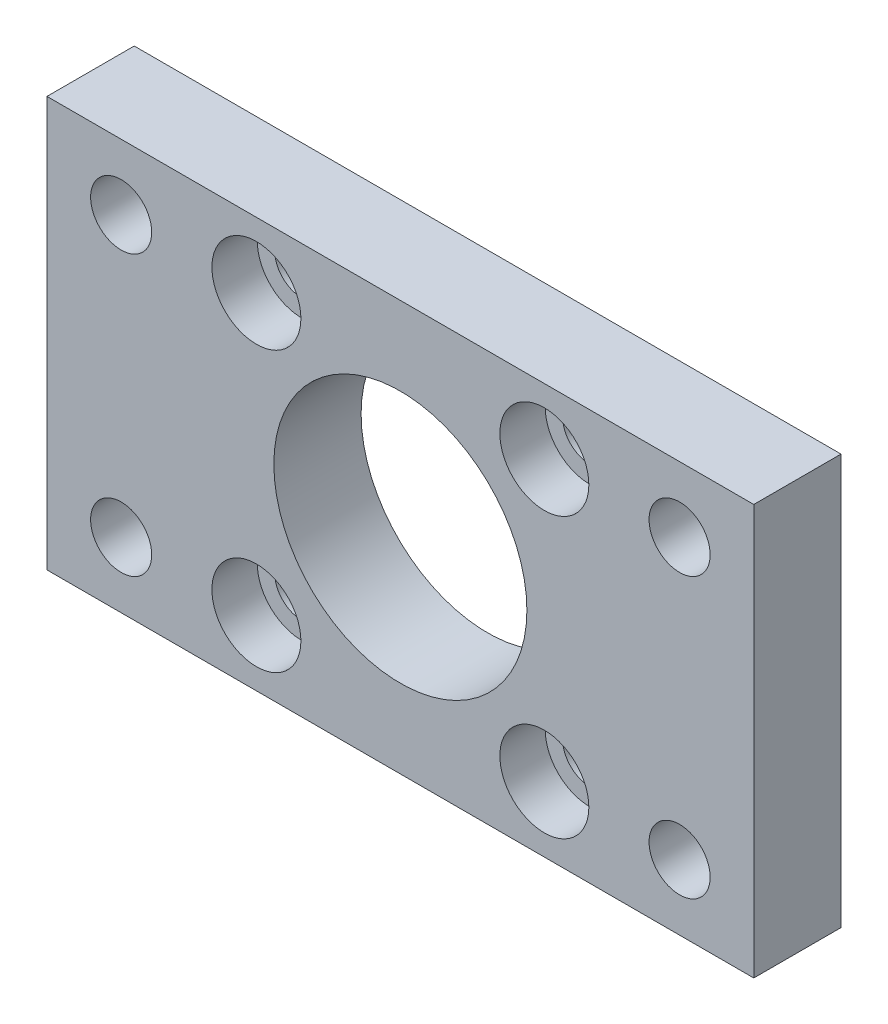
from build123d import *

# Parameters (mm, degrees)
ESQUISSE2_W             = 81
ESQUISSE2_H             = 47
ESQUISSE2_R             = 14.5
ESQUISSE2_R_2           = 3.5
ESQUISSE2_R_3           = 3.1
BOSS_EXTRU_1_DEPTH      = 10
ESQUISSE5_R             = 5.1
ENL_V_MAT_EXTRU_1_DEPTH = 5.2


with BuildPart() as part:
    # Esquisse2 → Boss.-Extru.1 (new body)
    with BuildSketch(Plane.XY):
        with Locations((40.5, 23.5)):
            Rectangle(ESQUISSE2_W, ESQUISSE2_H)
        with Locations((40.5, 23.5)):
            Circle(ESQUISSE2_R, mode=Mode.SUBTRACT)
        with Locations((8.5, 39.5)):
            Circle(ESQUISSE2_R_2, mode=Mode.SUBTRACT)
        with Locations((72.5, 39.5)):
            Circle(ESQUISSE2_R_2, mode=Mode.SUBTRACT)
        with Locations((72.5, 7.5)):
            Circle(ESQUISSE2_R_2, mode=Mode.SUBTRACT)
        with Locations((8.5, 7.5)):
            Circle(ESQUISSE2_R_2, mode=Mode.SUBTRACT)
        with Locations((24, 39.5)):
            Circle(ESQUISSE2_R_3, mode=Mode.SUBTRACT)
        with Locations(Location((57, 39.5, 0), (0, 0, 180))):  # turned: the seam where the file's is
            Circle(ESQUISSE2_R_3, mode=Mode.SUBTRACT)
        with Locations((57, 7.5)):
            Circle(ESQUISSE2_R_3, mode=Mode.SUBTRACT)
        with Locations(Location((24, 7.5, 0), (0, 0, 180))):  # turned: the seam where the file's is
            Circle(ESQUISSE2_R_3, mode=Mode.SUBTRACT)
    extrude(amount=BOSS_EXTRU_1_DEPTH)

    # Esquisse5 → Enlèv. mat.-Extru.1 (cut)
    with BuildSketch(Plane.XY.offset(10)):
        with Locations((24, 39.5)):
            Circle(ESQUISSE5_R)
        with Locations((24, 7.5)):
            Circle(ESQUISSE5_R)
        with Locations((57, 7.5)):
            Circle(ESQUISSE5_R)
        with Locations((57, 39.5)):
            Circle(ESQUISSE5_R)
    extrude(amount=-ENL_V_MAT_EXTRU_1_DEPTH, mode=Mode.SUBTRACT)


solid = part.part
